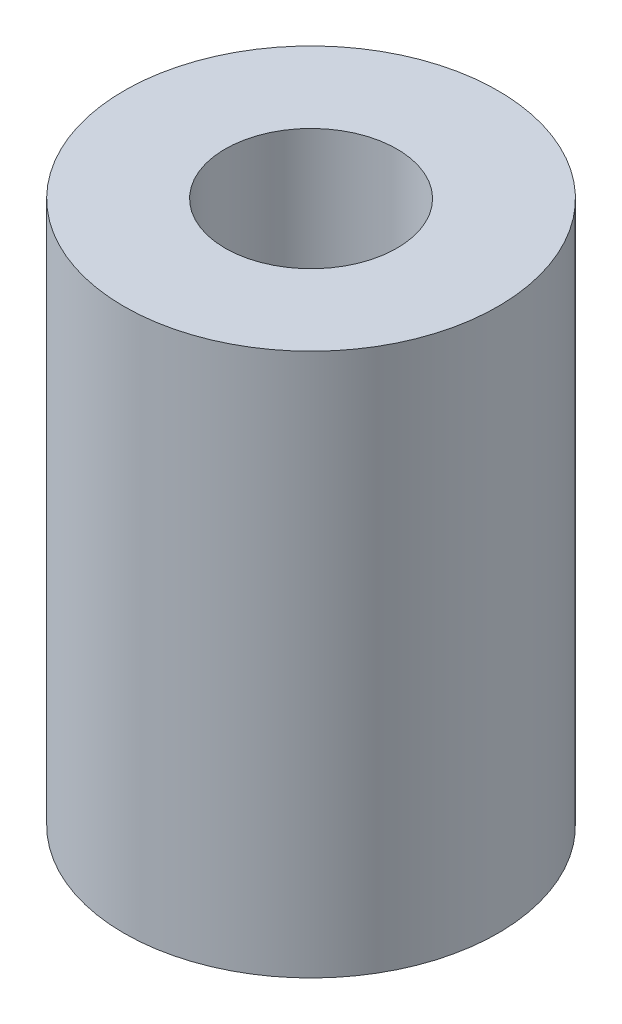
from build123d import *

# Parameters (mm, degrees)
SKETCH1_R           = 3.1
SKETCH1_R_2         = 1.425
BOSS_EXTRUDE1_DEPTH = 9


with BuildPart() as part:
    # Sketch1 → Boss-Extrude1 (new body)
    with BuildSketch(Plane(origin=(0, 0, 0), x_dir=(1, 0, 0), z_dir=(0, 1, 0))):
        Circle(SKETCH1_R)
        Circle(SKETCH1_R_2, mode=Mode.SUBTRACT)
    extrude(amount=BOSS_EXTRUDE1_DEPTH)


solid = part.part
